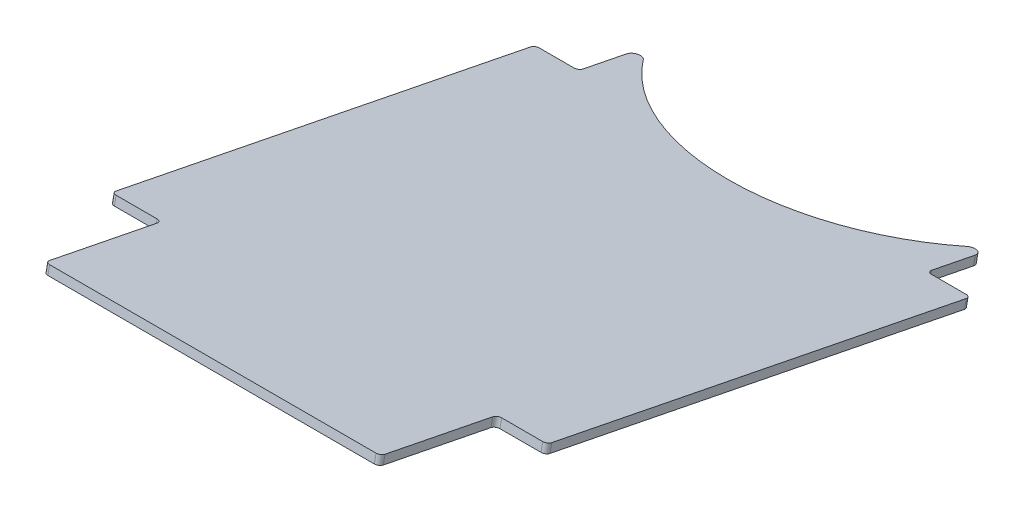
from build123d import *

# Parameters (mm, degrees)
BOSS_EXTRUDE1_DEPTH = 317.5
SKETCH2_W           = 31.75
SKETCH2_H           = 70.720826982
SKETCH2_W_2         = 36.5125
SKETCH2_H_2         = 48.495826983
CUT_EXTRUDE1_DEPTH  = 90.351177502
SKETCH5_W           = 244.475
SKETCH5_H           = 38.1
BOSS_EXTRUDE2_DEPTH = 6.35
CUT_EXTRUDE3_DEPTH  = 97.641296888
FILLET3_R           = 5.08
FILLET4_R           = 3.302


with BuildPart() as part:
    # Sketch1 → Boss-Extrude1 (new body)
    with BuildSketch(Plane(origin=(0, 0, 0), x_dir=(0, 0, -1), z_dir=(1, 0, 0))):
        Polygon((0, 38.1), (-1.238823545, 31.872013469), (-426.688823545, 116.499280171), (-425.45, 122.727266702), align=None)
    extrude(amount=BOSS_EXTRUDE1_DEPTH)

    # Sketch2 → Cut-Extrude1 (cut, through all)
    with BuildSketch(Plane(origin=(0, 36.649905094, -7.290119387), x_dir=(1, 0, 0), z_dir=(0, 0.98078528, -0.195090322))):
        with Locations((15.875, -42.79335476)):
            Rectangle(SKETCH2_W, SKETCH2_H)
        with Locations((18.25625, -416.970086038)):
            Rectangle(SKETCH2_W_2, SKETCH2_H_2)
        with Locations((301.625, -42.79335476)):
            Rectangle(SKETCH2_W, SKETCH2_H)
        with Locations((299.24375, -416.970086038)):
            Rectangle(SKETCH2_W_2, SKETCH2_H_2)
    extrude(amount=-CUT_EXTRUDE1_DEPTH, mode=Mode.SUBTRACT)

    # Sketch5 → Boss-Extrude2 (add)
    with BuildSketch(Plane(origin=(0, 30.421918564, -6.051295842), x_dir=(1, 0, 0), z_dir=(0, -0.98078528, 0.195090322))):
        with Locations((158.75, 460.267999529)):
            Rectangle(SKETCH5_W, SKETCH5_H)
    extrude(amount=-BOSS_EXTRUDE2_DEPTH)

    # Sketch6 → Cut-Extrude3 (cut, through all)
    with BuildSketch(Plane(origin=(0, 30.421918564, -6.051295842), x_dir=(1, 0, 0), z_dir=(0, -0.98078528, 0.195090322))):
        with BuildLine():
            Line((31.75, 26.482941269), (31.75, 7.432941269))
            Line((31.75, 7.432941269), (285.75, 7.432941269))
            Line((285.75, 7.432941269), (285.75, 26.482941269))
            ThreePointArc((285.75, 26.482941269), (158.75, 96.332941269), (31.75, 26.482941269))
        make_face()
    extrude(amount=-CUT_EXTRUDE3_DEPTH, mode=Mode.SUBTRACT)

    # Fillet3
    fillet3_edges = [part.edges().sort_by_distance(p)[0] for p in [
        (285.75, 38.702477369, 19.303371364),
        (31.75, 38.702477369, 19.303371364),
    ]]
    fillet(fillet3_edges, radius=FILLET3_R)

    # Fillet4
    fillet4_edges = [part.edges().sort_by_distance(p)[0] for p in [
        (0, 48.782955644, 69.981357895),
        (0, 110.152206934, 378.505418507),
        (317.5, 110.152206934, 378.505418507),
        (317.5, 48.782955644, 69.981357895),
        (36.5125, 110.152206934, 378.505418507),
        (285.75, 48.782955644, 69.981357895),
        (280.9875, 110.152206934, 378.505418507),
        (31.75, 48.782955644, 69.981357895),
        (36.5125, 127.046214705, 463.437330956),
        (280.9875, 127.046214705, 463.437330956),
    ]]
    fillet(fillet4_edges, radius=FILLET4_R)


solid = part.part
